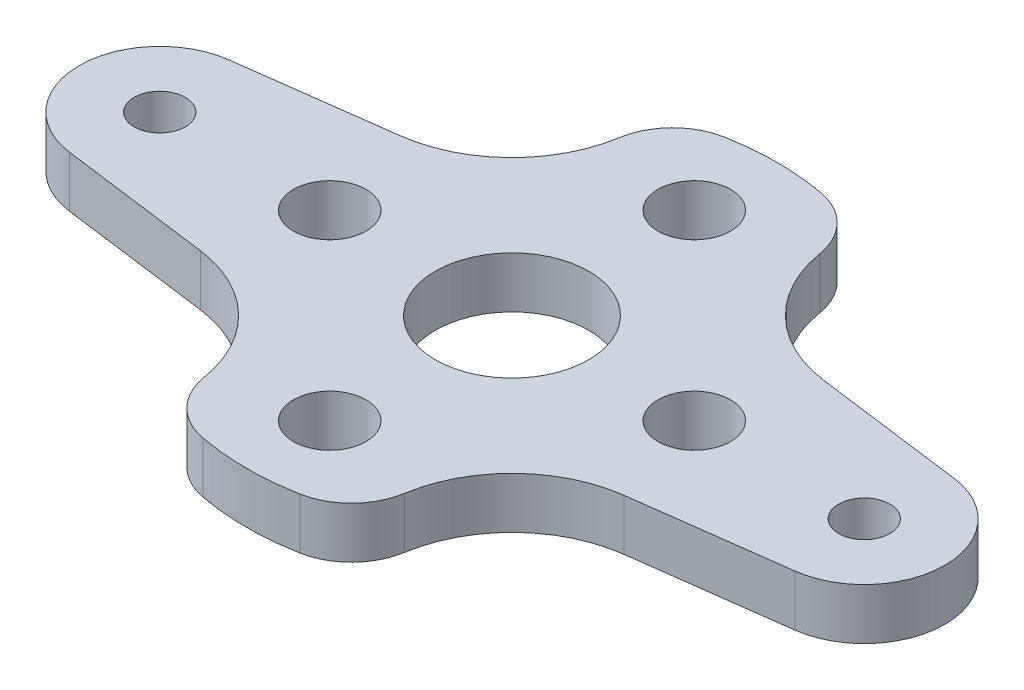
from build123d import *

# Parameters (mm, degrees)
BOSS_EXTRUDE1_DEPTH        = 3.175
F_1_8_0_1250_DOWEL_HOLE1_D = 3.175
SKETCH4_R                  = 4.7625
CUT_EXTRUDE1_DEPTH         = 4.175
M4_CLEARANCE_HOLE1_D       = 4.5
SKETCH7_R                  = 1.5875
CUT_EXTRUDE2_DEPTH         = 4.175
FILLET1_R                  = 4


with BuildPart() as part:
    # Sketch1 → Boss-Extrude1 (new body)
    with BuildSketch(Plane(origin=(0, 0, 0), x_dir=(1, 0, 0), z_dir=(0, 1, 0))):
        with BuildLine():
            Line((4.957224307, 22.517830961), (6.192571563, 13.134436958))
            ThreePointArc((6.192571563, 13.134436958), (8.485281374, 8.485281374), (13.134436958, 6.192571563))
            Line((13.134436958, 6.192571563), (22.517830961, 4.957224307))
            ThreePointArc((22.517830961, 4.957224307), (26.8652, 0), (22.517830961, -4.957224307))
            Line((22.517830961, -4.957224307), (13.134436958, -6.192571563))
            ThreePointArc((13.134436958, -6.192571563), (10.620595205, -6.955137122), (8.485281374, -8.485281374))
            Line((8.485281374, -8.485281374), (-8.485281374, 8.485281374))
            ThreePointArc((-8.485281374, 8.485281374), (-6.955137122, 10.620595205), (-6.192571563, 13.134436958))
            Line((-6.192571563, 13.134436958), (-4.957224307, 22.517830961))
            ThreePointArc((-4.957224307, 22.517830961), (0, 26.8652), (4.957224307, 22.517830961))
        make_face()
    boss_extrude1 = extrude(amount=BOSS_EXTRUDE1_DEPTH)

    # Mirror7: Boss-Extrude1 across plane
    add(boss_extrude1.mirror(Plane(origin=(-8.485281374, 3.175, -8.485281374), x_dir=(0.707106781, 0, 0.707106781), z_dir=(0.707106781, 0, -0.707106781))))

    # 1/8 (0.1250) Dowel Hole1 (through all)
    with Locations(Plane(origin=(0, 3.175, 0), x_dir=(1, 0, 0), z_dir=(0, 1, 0))):
        with Locations((0, 21.8652), (0, -21.8652), (-21.8652, 0), (21.8652, 0)):
            Hole(F_1_8_0_1250_DOWEL_HOLE1_D / 2)

    # Sketch4 → Cut-Extrude1 (cut, through all)
    with BuildSketch(Plane(origin=(0, 3.175, 0), x_dir=(1, 0, 0), z_dir=(0, 1, 0))):
        Circle(SKETCH4_R)
    extrude(amount=-CUT_EXTRUDE1_DEPTH, mode=Mode.SUBTRACT)

    # M4 Clearance Hole1 (through all)
    with Locations(Plane(origin=(0, 3.175, 0), x_dir=(1, 0, 0), z_dir=(0, 1, 0))):
        with Locations((-11.313708499, 0), (0, 11.313708499), (11.313708499, 0), (0, -11.313708499)):
            Hole(M4_CLEARANCE_HOLE1_D / 2)

    # Sketch7 → Cut-Extrude2 (cut, through all)
    with BuildSketch(Plane(origin=(0, 3.175, 0), x_dir=(1, 0, 0), z_dir=(0, 1, 0))):
        with BuildLine():
            ThreePointArc((4.957224307, 22.517830961), (0, 26.8652), (-4.957224307, 22.517830961))
            Line((-4.957224307, 22.517830961), (-5.898887631, 15.365187896))
            ThreePointArc((-5.898887631, 15.365187896), (0, 16.458610949), (5.898887631, 15.365187896))
            Line((5.898887631, 15.365187896), (4.957224307, 22.517830961))
        make_face()
        with Locations((0, 21.8652)):
            Circle(SKETCH7_R, mode=Mode.SUBTRACT)
        with BuildLine():
            ThreePointArc((5.898887631, -15.365187896), (0, -16.458610949), (-5.898887631, -15.365187896))
            Line((-5.898887631, -15.365187896), (-4.957224307, -22.517830961))
            ThreePointArc((-4.957224307, -22.517830961), (0, -26.8652), (4.957224307, -22.517830961))
            Line((4.957224307, -22.517830961), (5.898887631, -15.365187896))
        make_face()
        with Locations((0, -21.8652)):
            Circle(SKETCH7_R, mode=Mode.SUBTRACT)
    extrude(amount=-CUT_EXTRUDE2_DEPTH, mode=Mode.SUBTRACT)

    # Fillet1
    fillet1_edges = [part.edges().sort_by_distance(p)[0] for p in [
        (5.898887631, 1.5875, -15.365187896),
        (-5.898887631, 1.5875, -15.365187896),
        (-5.898887631, 1.5875, 15.365187896),
        (5.898887631, 1.5875, 15.365187896),
    ]]
    fillet(fillet1_edges, radius=FILLET1_R)


solid = part.part
